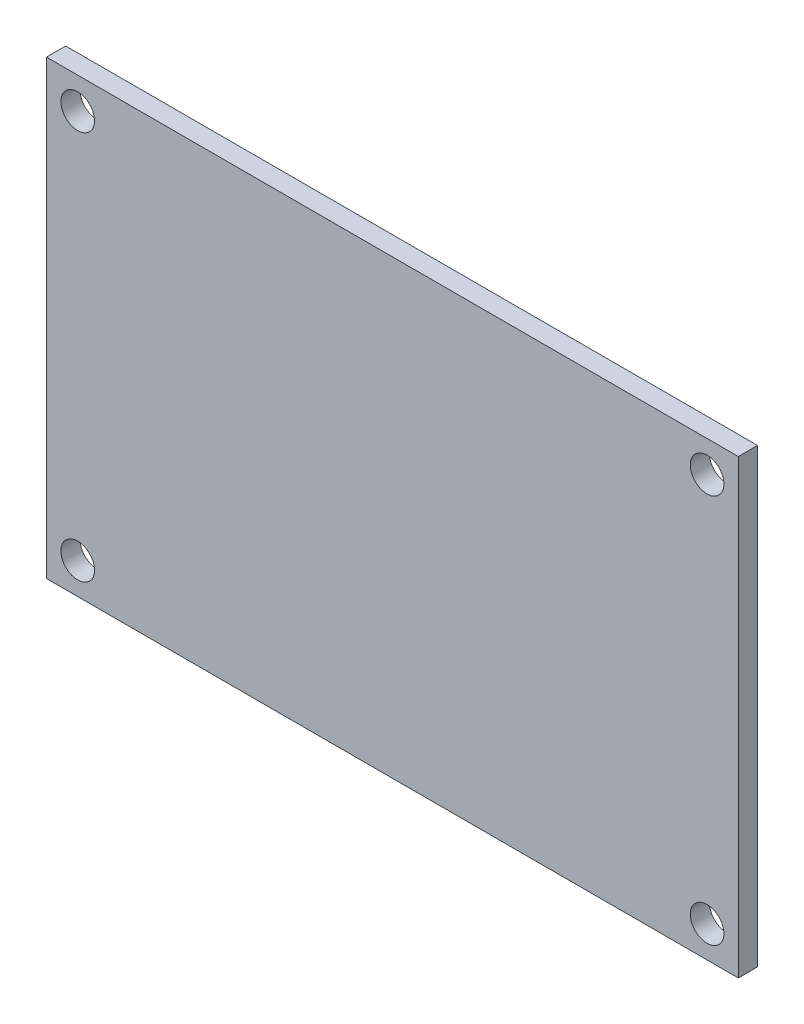
from build123d import *

# Parameters (mm, degrees)
SKETCH1_W               = 72
SKETCH1_H               = 47
BOSS_EXTRUDE1_DEPTH     = 2
SKETCH2_R               = 1.75
CUT_EXTRUDE1_DEPTH      = 3
CUT_EXTRUDE1_DEPTH_BACK = 1


with BuildPart() as part:
    # Sketch1 → Boss-Extrude1 (new body)
    with BuildSketch(Plane.XY):
        Rectangle(SKETCH1_W, SKETCH1_H)
    extrude(amount=BOSS_EXTRUDE1_DEPTH)

    # Sketch2 → Cut-Extrude1 (cut, two sides)
    with BuildSketch(Plane.XY) as cut_extrude1_sk:
        with Locations((-32.75, 20.25)):
            Circle(SKETCH2_R)
        with Locations((32.75, 20.25)):
            Circle(SKETCH2_R)
        with Locations((32.75, -20.25)):
            Circle(SKETCH2_R)
        with Locations((-32.75, -20.25)):
            Circle(SKETCH2_R)
    extrude(amount=CUT_EXTRUDE1_DEPTH, mode=Mode.SUBTRACT)
    extrude(cut_extrude1_sk.sketch, amount=-CUT_EXTRUDE1_DEPTH_BACK, mode=Mode.SUBTRACT)


solid = part.part
